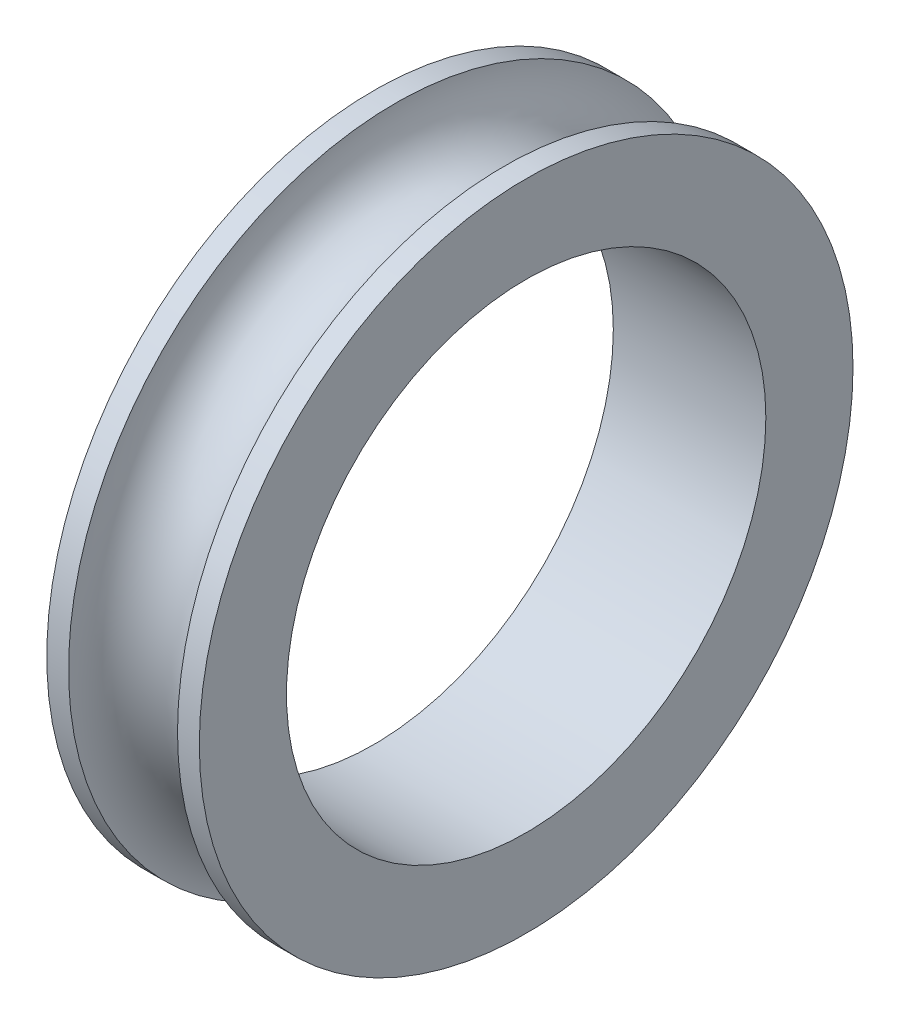
from build123d import *

# Parameters (mm, degrees)
ESBO_O1_R                = 15
ESBO_O1_R_2              = 11
RESSALTO_EXTRUS_O1_DEPTH = 7
ESBO_O2_R                = 2.5


with BuildPart() as part:
    # Esboço1 → Ressalto-extrusão1 (new body)
    with BuildSketch(Plane(origin=(0, 0, 0), x_dir=(0, 0, -1), z_dir=(1, 0, 0))):
        Circle(ESBO_O1_R)
        Circle(ESBO_O1_R_2, mode=Mode.SUBTRACT)
    extrude(amount=RESSALTO_EXTRUS_O1_DEPTH)

    # Esboço2 → Corte-Revolução1 (revolve, cut)
    with BuildSketch(Plane.XY):
        with Locations((3.5, 15)):
            Circle(ESBO_O2_R)
    revolve(axis=Axis((7, 0, 0), (-1, 0, 0)), mode=Mode.SUBTRACT)


solid = part.part
